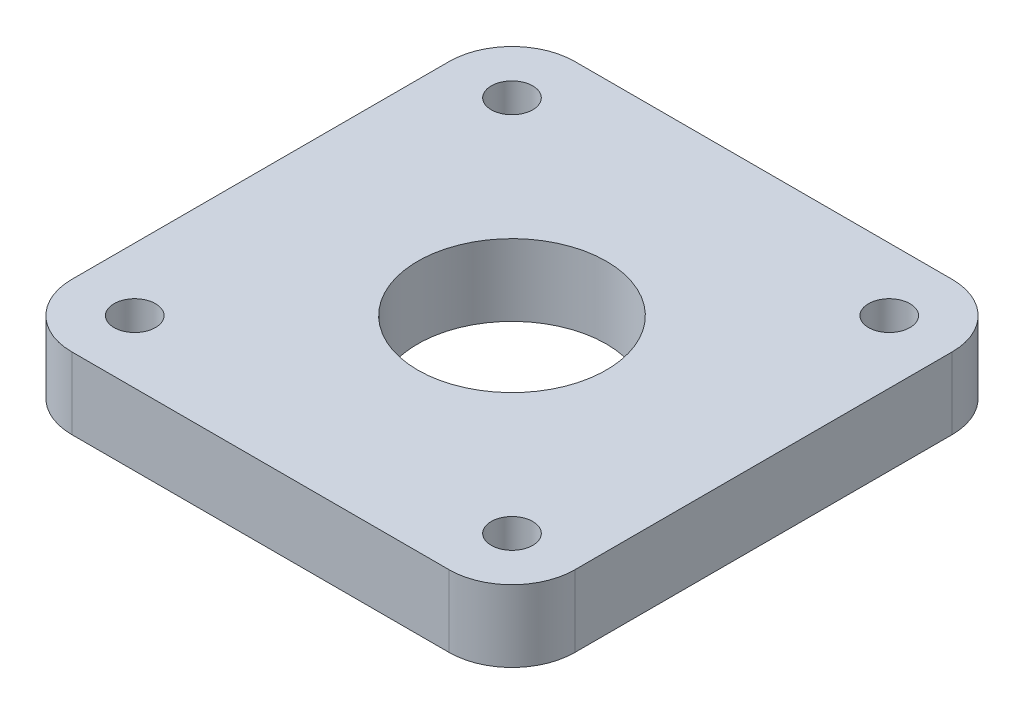
from build123d import *

# Parameters (mm, degrees)
BOSS_EXTRUDE1_DEPTH = 5.7
SKETCH2_R           = 7.5
SKETCH2_R_2         = 1.65
CUT_EXTRUDE1_DEPTH  = 6.7


with BuildPart() as part:
    # Sketch1 → Boss-Extrude1 (new body)
    with BuildSketch(Plane(origin=(0, 0, 0), x_dir=(1, 0, 0), z_dir=(0, 1, 0))):
        with BuildLine():
            Line((-15, -20), (15, -20))
            ThreePointArc((15, -20), (18.535533906, -18.535533906), (20, -15))
            Line((20, -15), (20, 15))
            ThreePointArc((20, 15), (18.535533906, 18.535533906), (15, 20))
            Line((15, 20), (-15, 20))
            ThreePointArc((-15, 20), (-18.535533906, 18.535533906), (-20, 15))
            Line((-20, 15), (-20, -15))
            ThreePointArc((-20, -15), (-18.535533906, -18.535533906), (-15, -20))
        make_face()
    extrude(amount=BOSS_EXTRUDE1_DEPTH)

    # Sketch2 → Cut-Extrude1 (cut, through all)
    with BuildSketch(Plane(origin=(0, 5.7, 0), x_dir=(1, 0, 0), z_dir=(0, 1, 0))):
        Circle(SKETCH2_R)
        with Locations((-15, 15)):
            Circle(SKETCH2_R_2)
        with Locations((15, 15)):
            Circle(SKETCH2_R_2)
        with Locations((15, -15)):
            Circle(SKETCH2_R_2)
        with Locations((-15, -15)):
            Circle(SKETCH2_R_2)
    extrude(amount=-CUT_EXTRUDE1_DEPTH, mode=Mode.SUBTRACT)


solid = part.part
